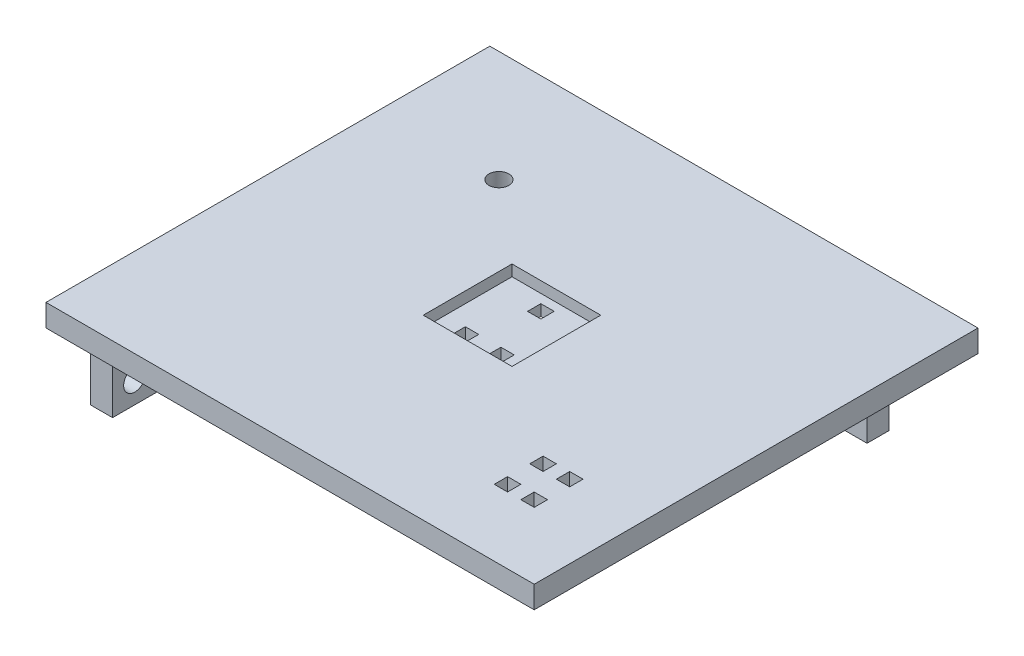
from build123d import *

# Parameters (mm, degrees)
SKETCH1_W           = 110
SKETCH1_H           = 100
SKETCH1_W_2         = 3
SKETCH1_H_2         = 3
BOSS_EXTRUDE1_DEPTH = 2.5
SKETCH2_W           = 110
SKETCH2_H           = 100
SKETCH2_W_2         = 20
SKETCH2_H_2         = 20
BOSS_EXTRUDE2_DEPTH = 2.5
SKETCH3_R           = 2.25
CUT_EXTRUDE1_DEPTH  = 6
CUT_EXTRUDE1_TAPER  = -8
SKETCH4_W           = 3
SKETCH4_H           = 3
CUT_EXTRUDE2_DEPTH  = 6.0000001
SKETCH5_W           = 10
SKETCH5_H           = 5
BOSS_EXTRUDE3_DEPTH = 20
SKETCH8_R           = 2.5
CUT_EXTRUDE4_DEPTH  = 15
SKETCH9_W           = 5
SKETCH9_H           = 10
BOSS_EXTRUDE4_DEPTH = 15
SKETCH10_R          = 2.5
CUT_EXTRUDE5_DEPTH  = 15


with BuildPart() as part:
    # Sketch1 → Boss-Extrude1 (new body)
    with BuildSketch(Plane(origin=(0, 0, 0), x_dir=(1, 0, 0), z_dir=(0, 1, 0))):
        with Locations((-55, 50)):
            Rectangle(SKETCH1_W, SKETCH1_H)
        with Locations((-59, 43.5)):
            Rectangle(SKETCH1_W_2, SKETCH1_H_2, mode=Mode.SUBTRACT)
        with Locations((-51, 43.5)):
            Rectangle(SKETCH1_W_2, SKETCH1_H_2, mode=Mode.SUBTRACT)
        with Locations((-55, 56.5)):
            Rectangle(SKETCH1_W_2, SKETCH1_H_2, mode=Mode.SUBTRACT)
    extrude(amount=BOSS_EXTRUDE1_DEPTH)

    # Sketch2 → Boss-Extrude2 (add)
    with BuildSketch(Plane(origin=(0, 2.5, 0), x_dir=(1, 0, 0), z_dir=(0, 1, 0))):
        with Locations((-55, 50)):
            Rectangle(SKETCH2_W, SKETCH2_H)
        with Locations((-55, 50)):
            Rectangle(SKETCH2_W_2, SKETCH2_H_2, mode=Mode.SUBTRACT)
    extrude(amount=BOSS_EXTRUDE2_DEPTH)

    # Sketch3 → Cut-Extrude1 (cut, through all)
    with BuildSketch(Plane(origin=(0, 5, 0), x_dir=(1, 0, 0), z_dir=(0, 1, 0))):
        with Locations((-82.921200256, 74.97538555)):
            Circle(SKETCH3_R)
    extrude(amount=-CUT_EXTRUDE1_DEPTH, taper=CUT_EXTRUDE1_TAPER, mode=Mode.SUBTRACT)

    # Sketch4 → Cut-Extrude2 (cut, through all)
    with BuildSketch(Plane(origin=(0, 5, 0), x_dir=(1, 0, 0), z_dir=(0, 1, 0))):
        with Locations((-22.5, 24.5)):
            Rectangle(SKETCH4_W, SKETCH4_H)
        with Locations((-16.5, 24.5)):
            Rectangle(SKETCH4_W, SKETCH4_H)
        with Locations((-22.5, 16.5)):
            Rectangle(SKETCH4_W, SKETCH4_H)
        with Locations((-16.5, 16.5)):
            Rectangle(SKETCH4_W, SKETCH4_H)
    extrude(amount=-CUT_EXTRUDE2_DEPTH, mode=Mode.SUBTRACT)

    # Sketch5 → Boss-Extrude3 (add)
    with BuildSketch(Plane(origin=(0, 5, 0), x_dir=(1, 0, 0), z_dir=(0, 1, 0))):
        with Locations((-15, 87.5)):
            Rectangle(SKETCH5_W, SKETCH5_H)
    extrude(amount=-BOSS_EXTRUDE3_DEPTH)

    # Sketch8 → Cut-Extrude4 (cut)
    with BuildSketch(Plane(origin=(0, 0, -90), x_dir=(-1, 0, 0), z_dir=(0, 0, -1))):
        with Locations((15, -10)):
            Circle(SKETCH8_R)
    extrude(amount=-CUT_EXTRUDE4_DEPTH, mode=Mode.SUBTRACT)

    # Sketch9 → Boss-Extrude4 (add)
    with BuildSketch(Plane.XZ):
        with Locations((-102.5, -10)):
            Rectangle(SKETCH9_W, SKETCH9_H)
    extrude(amount=BOSS_EXTRUDE4_DEPTH)

    # Sketch10 → Cut-Extrude5 (cut)
    with BuildSketch(Plane.ZY.offset(105)):
        with Locations((-10, -10)):
            Circle(SKETCH10_R)
    extrude(amount=-CUT_EXTRUDE5_DEPTH, mode=Mode.SUBTRACT)


solid = part.part
